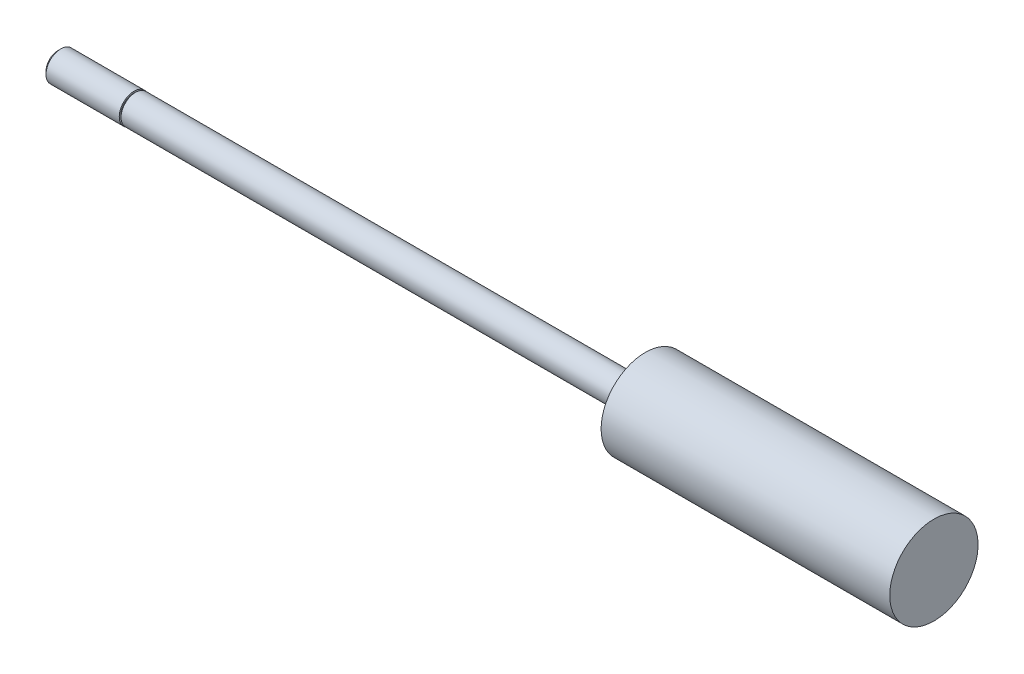
from build123d import *

# Parameters (mm, degrees)
SKETCH3_W = 0.254
SKETCH3_H = 0.508


with BuildPart() as part:
    # Sketch1 → Revolve1 (revolve)
    with BuildSketch(Plane.XY):
        Polygon((0, 0), (0, 2.3749), (83.3374, 2.3749), (83.3374, 7.21995), (130.5306, 7.21995), (130.5306, 0), align=None)
    revolve(axis=Axis((130.5306, 0, 0), (-1, 0, 0)))

    # Sketch2 → Revolve2 (revolve)
    with BuildSketch(Plane.XY):
        Polygon((-12.7, 0), (-12.7, 1.94056), (-12.22756, 2.413), (0, 2.413), (0, 0), align=None)
    revolve(axis=Axis((0, 0, 0), (-1, 0, 0)))

    # Sketch3 → Cut-Revolve1 (revolve, cut)
    with BuildSketch(Plane.XY):
        with Locations((-0.127, 2.413)):
            Rectangle(SKETCH3_W, SKETCH3_H)
    revolve(axis=Axis((0, 0, 0), (-1, 0, 0)), mode=Mode.SUBTRACT)


solid = part.part
